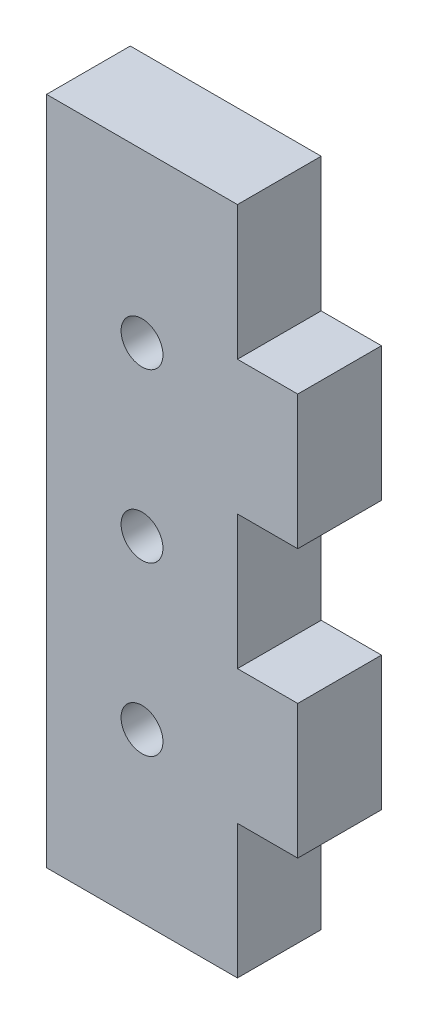
from build123d import *

# Parameters (mm, degrees)
SKETCH1_W           = 19.05
SKETCH1_H           = 50.8
BOSS_EXTRUDE1_DEPTH = 6.35
SKETCH2_W           = 4.572
SKETCH2_H           = 10.16
CUT_EXTRUDE1_DEPTH  = 7.35
SKETCH3_R           = 1.5875
CUT_EXTRUDE2_DEPTH  = 7.35


with BuildPart() as part:
    # Sketch1 → Boss-Extrude1 (new body)
    with BuildSketch(Plane.XY):
        with Locations((9.525, 25.4)):
            Rectangle(SKETCH1_W, SKETCH1_H)
    extrude(amount=BOSS_EXTRUDE1_DEPTH)

    # Sketch2 → Cut-Extrude1 (cut, through all)
    with BuildSketch(Plane.XY.offset(6.35)):
        with Locations((16.764, 45.72)):
            Rectangle(SKETCH2_W, SKETCH2_H)
        with Locations((16.764, 25.4)):
            Rectangle(SKETCH2_W, SKETCH2_H)
        with Locations((16.764, 5.08)):
            Rectangle(SKETCH2_W, SKETCH2_H)
    extrude(amount=-CUT_EXTRUDE1_DEPTH, mode=Mode.SUBTRACT)

    # Sketch3 → Cut-Extrude2 (cut, through all)
    with BuildSketch(Plane.XY.offset(6.35)):
        with Locations((7.239, 38.1)):
            Circle(SKETCH3_R)
        with Locations((7.239, 25.4)):
            Circle(SKETCH3_R)
        with Locations((7.239, 12.7)):
            Circle(SKETCH3_R)
    extrude(amount=-CUT_EXTRUDE2_DEPTH, mode=Mode.SUBTRACT)


solid = part.part
